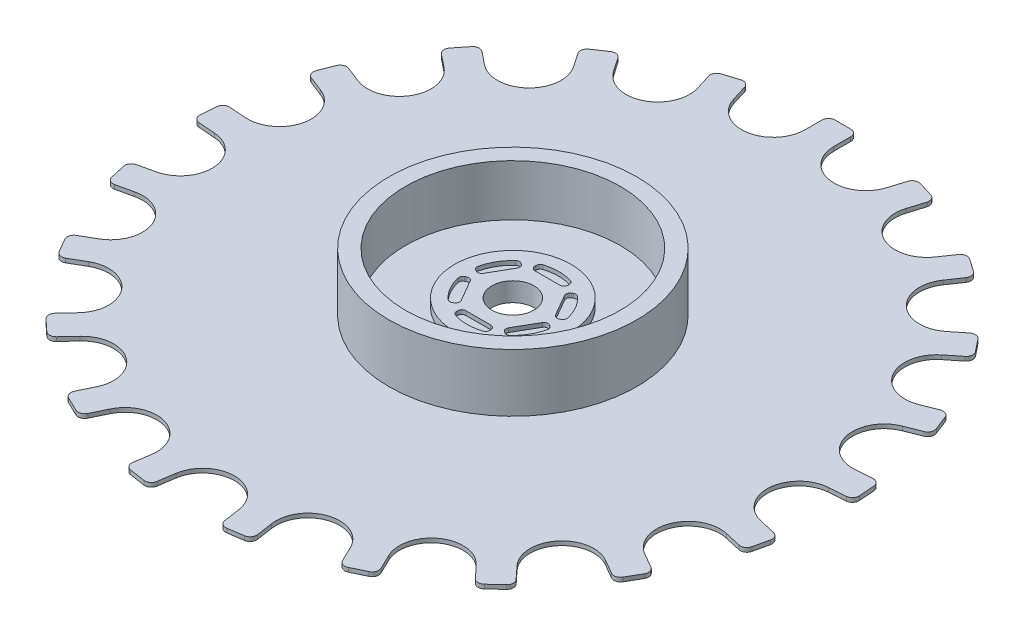
from build123d import *

# Parameters (mm, degrees)
RESSALTO_EXTRUS_O1_DEPTH = 0.25
ESBO_O2_R                = 1.745
RESSALTO_EXTRUS_O2_DEPTH = 4.625
PADR_OCIRCULAR1_COUNT    = 21
FILLET2_R                = 3.85
SKETCH2_R                = 15
BOSS_EXTRUDE1_DEPTH      = 7
SKETCH4_R                = 13
CUT_EXTRUDE2_DEPTH       = 6.2
SKETCH7_R                = 7.05
BOSS_EXTRUDE4_DEPTH      = 1
CUT_EXTRUDE3_DEPTH       = 0.5
SKETCH3_R                = 2.55
CUT_EXTRUDE1_DEPTH       = 8.25
CUT_EXTRUDE1_DEPTH_BACK  = 1.25


with BuildPart() as part:
    # Esboço1 → Ressalto-extrusão1 (new body, symmetric)
    with BuildSketch(Plane.XZ):
        with BuildLine():
            Line((-0.945, 0), (0.945, 0))
            ThreePointArc((0.945, 0), (1.510685425, -0.234314575), (1.745, -0.8))
            Line((1.745, -0.8), (1.745, -39.142))
            ThreePointArc((1.745, -39.142), (1.510685425, -39.707685425), (0.945, -39.942))
            Line((0.945, -39.942), (-0.945, -39.942))
            ThreePointArc((-0.945, -39.942), (-1.510685425, -39.707685425), (-1.745, -39.142))
            Line((-1.745, -39.142), (-1.745, -0.8))
            ThreePointArc((-1.745, -0.8), (-1.510685425, -0.234314575), (-0.945, 0))
        make_face()
    ressalto_extrus_o1 = extrude(amount=RESSALTO_EXTRUS_O1_DEPTH, both=True)

    # Esboço2 → Ressalto-extrusão2 (add)
    with BuildSketch(Plane(origin=(0, 0, 0), x_dir=(1, 0, 0), z_dir=(0, 1, 0))):
        Circle(ESBO_O2_R)
    extrude(amount=RESSALTO_EXTRUS_O2_DEPTH)

    # PadrãoCircular1: Ressalto-extrusão1 ×21 about axis
    padr_ocircular1_axis = Axis((0, 0, 0), (0, 1, 0))
    for i in range(1, PADR_OCIRCULAR1_COUNT):
        add(ressalto_extrus_o1.rotate(padr_ocircular1_axis, i * 360 / PADR_OCIRCULAR1_COUNT))

    # Fillet2
    fillet2_edges = [part.edges().sort_by_distance(p)[0] for p in [
        (-1.745, 0, -11.577318542),
        (1.745, 0, -11.577318542),
        (0, 0, 11.708088214),
        (7.963522415, 0, -8.582635981),
        (5.079949092, 0, -10.548622983),
        (-3.451019584, 0, 11.187930705),
        (-9.153751965, 0, 7.299873601),
        (-6.595400933, 0, 9.673676455),
        (-11.675350025, 0, 0.874946528),
        (-11.414541998, 0, -2.605294724),
        (-10.898751965, 0, 4.277444941),
        (10.139501823, 0, -5.854044107),
        (11.675350025, 0, 0.874946528),
        (11.414541998, 0, -2.605294724),
        (9.153751965, 0, 7.299873601),
        (6.595400933, 0, 9.673676455),
        (10.898751965, 0, 4.277444941),
        (3.451019584, 0, 11.187930705),
        (-5.079949092, 0, -10.548622983),
        (-10.139501823, 0, -5.854044107),
        (-7.963522415, 0, -8.582635981),
    ]]
    fillet(fillet2_edges, radius=FILLET2_R)

    # Sketch2 → Boss-Extrude1 (add)
    with BuildSketch(Plane(origin=(0, 0.25, 0), x_dir=(1, 0, 0), z_dir=(0, 1, 0))):
        Circle(SKETCH2_R)
    extrude(amount=BOSS_EXTRUDE1_DEPTH)

    # Sketch4 → Cut-Extrude2 (cut)
    with BuildSketch(Plane(origin=(0, 7.25, 0), x_dir=(1, 0, 0), z_dir=(0, 1, 0))):
        Circle(SKETCH4_R)
    extrude(amount=-CUT_EXTRUDE2_DEPTH, mode=Mode.SUBTRACT)

    # Sketch7 → Boss-Extrude4 (add)
    with BuildSketch(Plane(origin=(0, 1.05, 0), x_dir=(1, 0, 0), z_dir=(0, 1, 0))):
        Circle(SKETCH7_R)
    extrude(amount=BOSS_EXTRUDE4_DEPTH)

    # Sketch9 → Cut-Extrude3 (cut)
    with BuildSketch(Plane(origin=(0, 2.05, 0), x_dir=(1, 0, 0), z_dir=(0, 1, 0))):
        with BuildLine():
            Line((-2, -4.822084611), (-2, -4.677113095))
            ThreePointArc((-2, -4.677113095), (-1.853553391, -4.323559705), (-1.5, -4.177113095))
            Line((-1.5, -4.177113095), (1.5, -4.177113095))
            ThreePointArc((1.5, -4.177113095), (1.853553391, -4.323559705), (2, -4.677113095))
            Line((2, -4.677113095), (2, -4.822084611))
            ThreePointArc((2, -4.822084611), (1.902652099, -5.118515526), (1.648514851, -5.299518731))
            ThreePointArc((1.648514851, -5.299518731), (0, -5.55), (-1.648514851, -5.299518731))
            ThreePointArc((-1.648514851, -5.299518731), (-1.902652099, -5.118515526), (-2, -4.822084611))
        make_face()
        with BuildLine():
            Line((-5.176047773, -0.678991498), (-5.050498757, -0.60650574))
            ThreePointArc((-5.050498757, -0.60650574), (-4.671089234, -0.556555529), (-4.367486055, -0.789518442))
            Line((-4.367486055, -0.789518442), (-2.867486055, -3.387594653))
            ThreePointArc((-2.867486055, -3.387594653), (-2.817535844, -3.767004176), (-3.050498757, -4.070607355))
            Line((-3.050498757, -4.070607355), (-3.176047773, -4.143093113))
            ThreePointArc((-3.176047773, -4.143093113), (-3.481438426, -4.207002815), (-3.765260423, -4.077415106))
            ThreePointArc((-3.765260423, -4.077415106), (-4.806440991, -2.775), (-5.413775275, -1.222103626))
            ThreePointArc((-5.413775275, -1.222103626), (-5.384090525, -0.911512711), (-5.176047773, -0.678991498))
        make_face()
        with BuildLine():
            Line((-3.176047773, 4.143093113), (-3.050498757, 4.070607355))
            ThreePointArc((-3.050498757, 4.070607355), (-2.817535844, 3.767004176), (-2.867486055, 3.387594653))
            Line((-2.867486055, 3.387594653), (-4.367486055, 0.789518442))
            ThreePointArc((-4.367486055, 0.789518442), (-4.671089234, 0.556555529), (-5.050498757, 0.60650574))
            Line((-5.050498757, 0.60650574), (-5.176047773, 0.678991498))
            ThreePointArc((-5.176047773, 0.678991498), (-5.384090525, 0.911512711), (-5.413775275, 1.222103626))
            ThreePointArc((-5.413775275, 1.222103626), (-4.806440991, 2.775), (-3.765260423, 4.077415106))
            ThreePointArc((-3.765260423, 4.077415106), (-3.481438426, 4.207002815), (-3.176047773, 4.143093113))
        make_face()
        with BuildLine():
            Line((2, 4.822084611), (2, 4.677113095))
            ThreePointArc((2, 4.677113095), (1.853553391, 4.323559705), (1.5, 4.177113095))
            Line((1.5, 4.177113095), (-1.5, 4.177113095))
            ThreePointArc((-1.5, 4.177113095), (-1.853553391, 4.323559705), (-2, 4.677113095))
            Line((-2, 4.677113095), (-2, 4.822084611))
            ThreePointArc((-2, 4.822084611), (-1.902652099, 5.118515526), (-1.648514851, 5.299518731))
            ThreePointArc((-1.648514851, 5.299518731), (0, 5.55), (1.648514851, 5.299518731))
            ThreePointArc((1.648514851, 5.299518731), (1.902652099, 5.118515526), (2, 4.822084611))
        make_face()
        with BuildLine():
            Line((5.176047773, 0.678991498), (5.050498757, 0.60650574))
            ThreePointArc((5.050498757, 0.60650574), (4.671089234, 0.556555529), (4.367486055, 0.789518442))
            Line((4.367486055, 0.789518442), (2.867486055, 3.387594653))
            ThreePointArc((2.867486055, 3.387594653), (2.817535844, 3.767004176), (3.050498757, 4.070607355))
            Line((3.050498757, 4.070607355), (3.176047773, 4.143093113))
            ThreePointArc((3.176047773, 4.143093113), (3.481438426, 4.207002815), (3.765260423, 4.077415106))
            ThreePointArc((3.765260423, 4.077415106), (4.806440991, 2.775), (5.413775275, 1.222103626))
            ThreePointArc((5.413775275, 1.222103626), (5.384090525, 0.911512711), (5.176047773, 0.678991498))
        make_face()
        with BuildLine():
            Line((3.176047773, -4.143093113), (3.050498757, -4.070607355))
            ThreePointArc((3.050498757, -4.070607355), (2.817535844, -3.767004176), (2.867486055, -3.387594653))
            Line((2.867486055, -3.387594653), (4.367486055, -0.789518442))
            ThreePointArc((4.367486055, -0.789518442), (4.671089234, -0.556555529), (5.050498757, -0.60650574))
            Line((5.050498757, -0.60650574), (5.176047773, -0.678991498))
            ThreePointArc((5.176047773, -0.678991498), (5.384090525, -0.911512711), (5.413775275, -1.222103626))
            ThreePointArc((5.413775275, -1.222103626), (4.806440991, -2.775), (3.765260423, -4.077415106))
            ThreePointArc((3.765260423, -4.077415106), (3.481438426, -4.207002815), (3.176047773, -4.143093113))
        make_face()
    extrude(amount=-CUT_EXTRUDE3_DEPTH, mode=Mode.SUBTRACT)

    # Sketch3 → Cut-Extrude1 (cut, two sides)
    with BuildSketch(Plane(origin=(0, 0, 0), x_dir=(1, 0, 0), z_dir=(0, 1, 0))) as cut_extrude1_sk:
        Circle(SKETCH3_R)
    extrude(amount=CUT_EXTRUDE1_DEPTH, mode=Mode.SUBTRACT)
    extrude(cut_extrude1_sk.sketch, amount=-CUT_EXTRUDE1_DEPTH_BACK, mode=Mode.SUBTRACT)


solid = part.part
